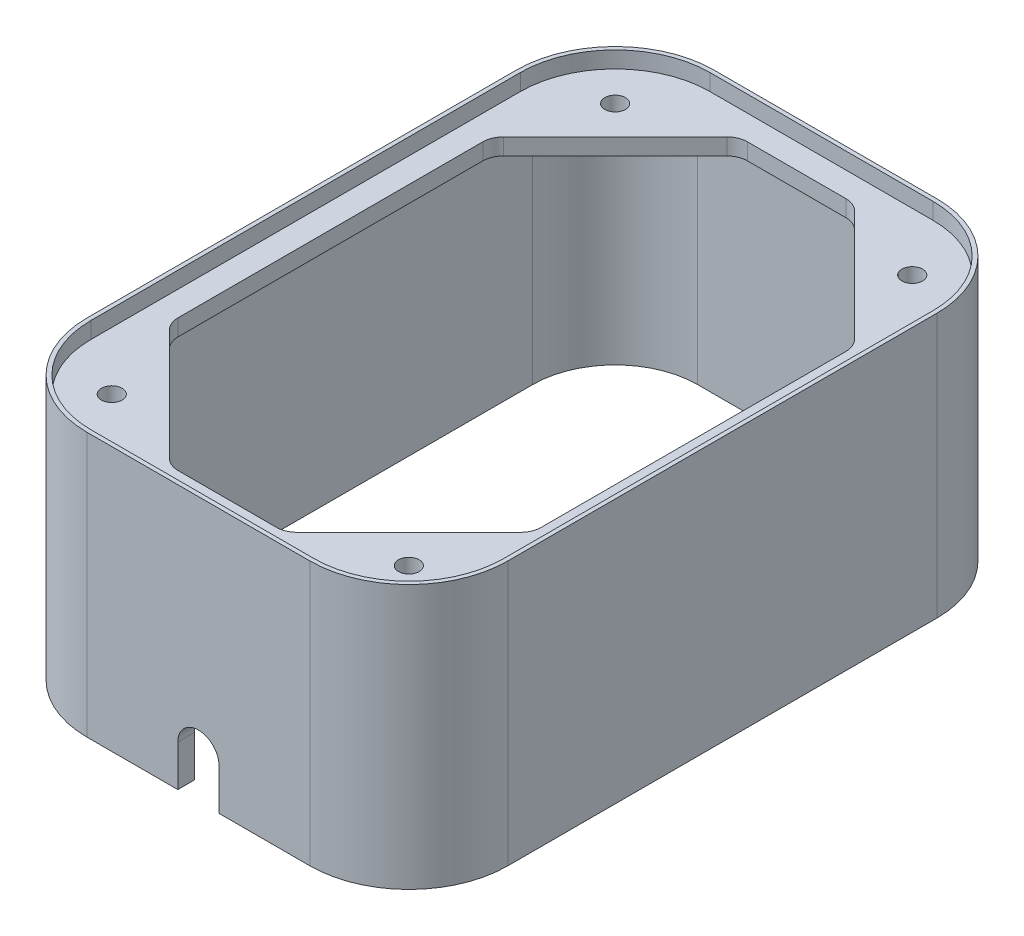
from build123d import *

# Parameters (mm, degrees)
SKETCH1_R           = 2.5
BOSS_EXTRUDE1_DEPTH = 4
BOSS_EXTRUDE2_DEPTH = 4
BOSS_EXTRUDE3_DEPTH = 56
CUT_EXTRUDE1_REACH  = 154
FILLET1_R           = 2


with BuildPart() as part:
    # Sketch1 → Boss-Extrude1 (new body)
    with BuildSketch(Plane(origin=(0, 0, 0), x_dir=(1, 0, 0), z_dir=(0, 1, 0))):
        with BuildLine():
            Line((-51, -52), (-51, 52))
            ThreePointArc((-51, 52), (-43.970562748, 68.970562748), (-27, 76))
            Line((-27, 76), (27, 76))
            ThreePointArc((27, 76), (43.970562748, 68.970562748), (51, 52))
            Line((51, 52), (51, -52))
            ThreePointArc((51, -52), (43.970562748, -68.970562748), (27, -76))
            Line((27, -76), (-27, -76))
            ThreePointArc((-27, -76), (-43.970562748, -68.970562748), (-51, -52))
        make_face()
        with Locations((-36, 61)):
            Circle(SKETCH1_R, mode=Mode.SUBTRACT)
        with Locations((-36, -61)):
            Circle(SKETCH1_R, mode=Mode.SUBTRACT)
        with Locations((36, -61)):
            Circle(SKETCH1_R, mode=Mode.SUBTRACT)
        with Locations((36, 61)):
            Circle(SKETCH1_R, mode=Mode.SUBTRACT)
        with BuildLine():
            Line((-44, -36.928932188), (-44, 36.928932188))
            ThreePointArc((-44, 36.928932188), (-43.619397663, 38.84234935), (-42.535533906, 40.464466094))
            Line((-42.535533906, 40.464466094), (-15.464466094, 67.535533906))
            ThreePointArc((-15.464466094, 67.535533906), (-13.84234935, 68.619397663), (-11.928932188, 69))
            Line((-11.928932188, 69), (11.928932188, 69))
            ThreePointArc((11.928932188, 69), (13.84234935, 68.619397663), (15.464466094, 67.535533906))
            Line((15.464466094, 67.535533906), (42.535533906, 40.464466094))
            ThreePointArc((42.535533906, 40.464466094), (43.619397663, 38.84234935), (44, 36.928932188))
            Line((44, 36.928932188), (44, -36.928932188))
            ThreePointArc((44, -36.928932188), (43.619397663, -38.84234935), (42.535533906, -40.464466094))
            Line((42.535533906, -40.464466094), (15.464466094, -67.535533906))
            ThreePointArc((15.464466094, -67.535533906), (13.84234935, -68.619397663), (11.928932188, -69))
            Line((11.928932188, -69), (-11.928932188, -69))
            ThreePointArc((-11.928932188, -69), (-13.84234935, -68.619397663), (-15.464466094, -67.535533906))
            Line((-15.464466094, -67.535533906), (-42.535533906, -40.464466094))
            ThreePointArc((-42.535533906, -40.464466094), (-43.619397663, -38.84234935), (-44, -36.928932188))
        make_face(mode=Mode.SUBTRACT)
    extrude(amount=-BOSS_EXTRUDE1_DEPTH)

    # Sketch2 → Boss-Extrude2 (add)
    with BuildSketch(Plane(origin=(0, 0, 0), x_dir=(1, 0, 0), z_dir=(0, 1, 0))):
        with BuildLine():
            Line((-27, -76), (27, -76))
            ThreePointArc((27, -76), (43.970562748, -68.970562748), (51, -52))
            Line((51, -52), (51, 52))
            ThreePointArc((51, 52), (43.970562748, 68.970562748), (27, 76))
            Line((27, 76), (-27, 76))
            ThreePointArc((-27, 76), (-43.970562748, 68.970562748), (-51, 52))
            Line((-51, 52), (-51, -52))
            ThreePointArc((-51, -52), (-43.970562748, -68.970562748), (-27, -76))
        make_face()
        with BuildLine():
            Line((-50, 52), (-50, -52))
            ThreePointArc((-50, -52), (-43.263455967, -68.263455967), (-27, -75))
            Line((-27, -75), (27, -75))
            ThreePointArc((27, -75), (43.263455967, -68.263455967), (50, -52))
            Line((50, -52), (50, 52))
            ThreePointArc((50, 52), (43.263455967, 68.263455967), (27, 75))
            Line((27, 75), (-27, 75))
            ThreePointArc((-27, 75), (-43.263455967, 68.263455967), (-50, 52))
        make_face(mode=Mode.SUBTRACT)
    extrude(amount=BOSS_EXTRUDE2_DEPTH)

    # Sketch3 → Boss-Extrude3 (add)
    with BuildSketch(Plane.XZ.offset(4)):
        with BuildLine():
            Line((-51, -52), (-51, 52))
            ThreePointArc((-51, 52), (-43.970562748, 68.970562748), (-27, 76))
            Line((-27, 76), (27, 76))
            ThreePointArc((27, 76), (43.970562748, 68.970562748), (51, 52))
            Line((51, 52), (51, -52))
            ThreePointArc((51, -52), (43.970562748, -68.970562748), (27, -76))
            Line((27, -76), (-27, -76))
            ThreePointArc((-27, -76), (-43.970562748, -68.970562748), (-51, -52))
        make_face()
        with BuildLine():
            Line((-47, -52), (-47, 52))
            ThreePointArc((-47, 52), (-41.142135624, 66.142135624), (-27, 72))
            Line((-27, 72), (27, 72))
            ThreePointArc((27, 72), (41.142135624, 66.142135624), (47, 52))
            Line((47, 52), (47, -52))
            ThreePointArc((47, -52), (41.142135624, -66.142135624), (27, -72))
            Line((27, -72), (-27, -72))
            ThreePointArc((-27, -72), (-41.142135624, -66.142135624), (-47, -52))
        make_face(mode=Mode.SUBTRACT)
    extrude(amount=BOSS_EXTRUDE3_DEPTH)

    # Sketch4 → Cut-Extrude1 (cut, up to next)
    with BuildSketch(Plane.XY.offset(76), mode=Mode.PRIVATE) as cut_extrude1_sk1:
        with BuildLine():
            Line((5, -60), (-5, -60))
            Line((-5, -60), (-5, -50))
            ThreePointArc((-5, -50), (0, -45), (5, -50))
            Line((5, -50), (5, -60))
        make_face()
    cut_extrude1_tool1 = extrude(cut_extrude1_sk1.sketch, amount=-CUT_EXTRUDE1_REACH, mode=Mode.PRIVATE) & part.part
    add(cut_extrude1_tool1.solids().sort_by_distance((0, -52.991792, 76))[0], mode=Mode.SUBTRACT)

    # Fillet1
    fillet1_edges = [part.edges().sort_by_distance(p)[0] for p in [
        (-41.142135624, -4, -66.142135624),
        (0, -4, -72),
        (41.142135624, -4, -66.142135624),
        (47, -4, 0),
        (41.142135624, -4, 66.142135624),
        (0, -4, 72),
        (-41.142135624, -4, 66.142135624),
        (-47, -4, 0),
    ]]
    fillet(fillet1_edges, radius=FILLET1_R)


solid = part.part
